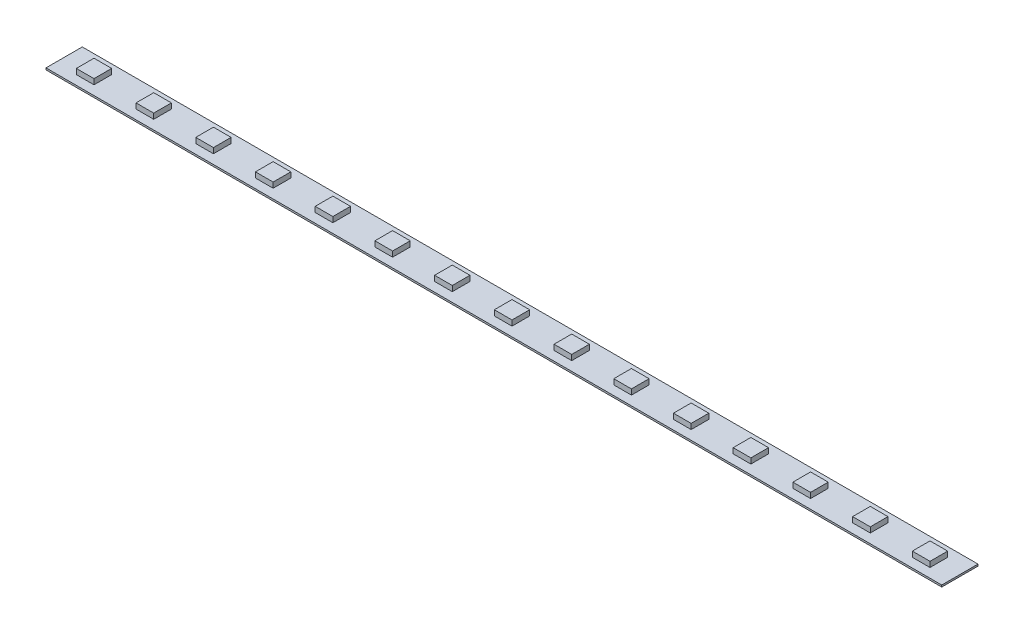
from build123d import *

# Parameters (mm, degrees)
SKETCH1_W           = 4.92
SKETCH1_H           = 4.92
BOSS_EXTRUDE1_DEPTH = 2
LPATTERN1_COUNT     = 15
LPATTERN1_PITCH     = 16.63
SKETCH2_W           = 249.45
SKETCH2_H           = 10.1
BOSS_EXTRUDE2_DEPTH = 0.5


with BuildPart() as part:
    # Sketch1 → Boss-Extrude1 (new body)
    with BuildSketch(Plane(origin=(0, 0, 0), x_dir=(1, 0, 0), z_dir=(0, 1, 0))):
        Rectangle(SKETCH1_W, SKETCH1_H)
    extrude(amount=BOSS_EXTRUDE1_DEPTH)


with BuildPart() as lpattern1_1:
    # LPattern1: pattern copy
    add(part.part.moved(Location(Vector(1, 0, 0) * (1 * LPATTERN1_PITCH))))


with BuildPart() as lpattern1_2:
    # LPattern1: pattern copy
    add(part.part.moved(Location(Vector(1, 0, 0) * (2 * LPATTERN1_PITCH))))


with BuildPart() as lpattern1_3:
    # LPattern1: pattern copy
    add(part.part.moved(Location(Vector(1, 0, 0) * (3 * LPATTERN1_PITCH))))


with BuildPart() as lpattern1_4:
    # LPattern1: pattern copy
    add(part.part.moved(Location(Vector(1, 0, 0) * (4 * LPATTERN1_PITCH))))


with BuildPart() as lpattern1_5:
    # LPattern1: pattern copy
    add(part.part.moved(Location(Vector(1, 0, 0) * (5 * LPATTERN1_PITCH))))


with BuildPart() as lpattern1_6:
    # LPattern1: pattern copy
    add(part.part.moved(Location(Vector(1, 0, 0) * (6 * LPATTERN1_PITCH))))


with BuildPart() as lpattern1_7:
    # LPattern1: pattern copy
    add(part.part.moved(Location(Vector(1, 0, 0) * (7 * LPATTERN1_PITCH))))


with BuildPart() as lpattern1_8:
    # LPattern1: pattern copy
    add(part.part.moved(Location(Vector(1, 0, 0) * (8 * LPATTERN1_PITCH))))


with BuildPart() as lpattern1_9:
    # LPattern1: pattern copy
    add(part.part.moved(Location(Vector(1, 0, 0) * (9 * LPATTERN1_PITCH))))


with BuildPart() as lpattern1_10:
    # LPattern1: pattern copy
    add(part.part.moved(Location(Vector(1, 0, 0) * (10 * LPATTERN1_PITCH))))


with BuildPart() as lpattern1_11:
    # LPattern1: pattern copy
    add(part.part.moved(Location(Vector(1, 0, 0) * (11 * LPATTERN1_PITCH))))


with BuildPart() as lpattern1_12:
    # LPattern1: pattern copy
    add(part.part.moved(Location(Vector(1, 0, 0) * (12 * LPATTERN1_PITCH))))


with BuildPart() as lpattern1_13:
    # LPattern1: pattern copy
    add(part.part.moved(Location(Vector(1, 0, 0) * (13 * LPATTERN1_PITCH))))


with BuildPart() as lpattern1_14:
    # LPattern1: pattern copy
    add(part.part.moved(Location(Vector(1, 0, 0) * (14 * LPATTERN1_PITCH))))


with BuildPart() as part_1:
    add(part.part)

    add(lpattern1_1.part)  # Boss-Extrude2 merges LPattern1_1

    add(lpattern1_2.part)  # Boss-Extrude2 merges LPattern1_2

    add(lpattern1_3.part)  # Boss-Extrude2 merges LPattern1_3

    add(lpattern1_4.part)  # Boss-Extrude2 merges LPattern1_4

    add(lpattern1_5.part)  # Boss-Extrude2 merges LPattern1_5

    add(lpattern1_6.part)  # Boss-Extrude2 merges LPattern1_6

    add(lpattern1_7.part)  # Boss-Extrude2 merges LPattern1_7

    add(lpattern1_8.part)  # Boss-Extrude2 merges LPattern1_8

    add(lpattern1_9.part)  # Boss-Extrude2 merges LPattern1_9

    add(lpattern1_10.part)  # Boss-Extrude2 merges LPattern1_10

    add(lpattern1_11.part)  # Boss-Extrude2 merges LPattern1_11

    add(lpattern1_12.part)  # Boss-Extrude2 merges LPattern1_12

    add(lpattern1_13.part)  # Boss-Extrude2 merges LPattern1_13

    add(lpattern1_14.part)  # Boss-Extrude2 merges LPattern1_14
    # Sketch2 → Boss-Extrude2 (add)
    with BuildSketch(Plane(origin=(0, 0, 0), x_dir=(1, 0, 0), z_dir=(0, 1, 0))):
        with Locations((116.41, 0)):
            Rectangle(SKETCH2_W, SKETCH2_H)
    extrude(amount=BOSS_EXTRUDE2_DEPTH)


solid = part_1.part
